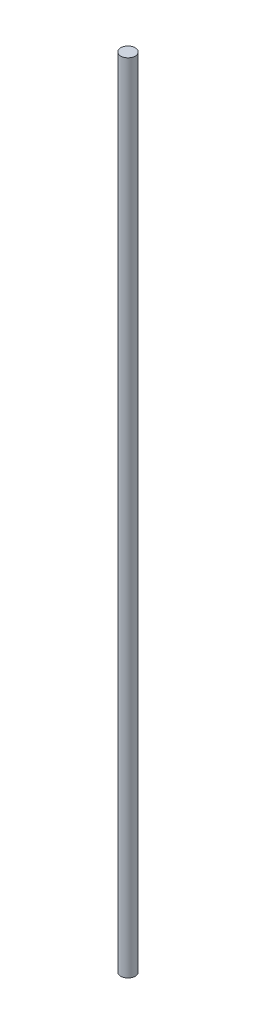
from build123d import *

# Parameters (mm, degrees)
SKETCH1_R           = 2
BOSS_EXTRUDE1_DEPTH = 220


with BuildPart() as part:
    # Sketch1 → Boss-Extrude1 (new body)
    with BuildSketch(Plane(origin=(0, 0, 0), x_dir=(1, 0, 0), z_dir=(0, 1, 0))):
        with Locations((-18.841591662, 0)):
            Circle(SKETCH1_R)
    extrude(amount=BOSS_EXTRUDE1_DEPTH)


solid = part.part
